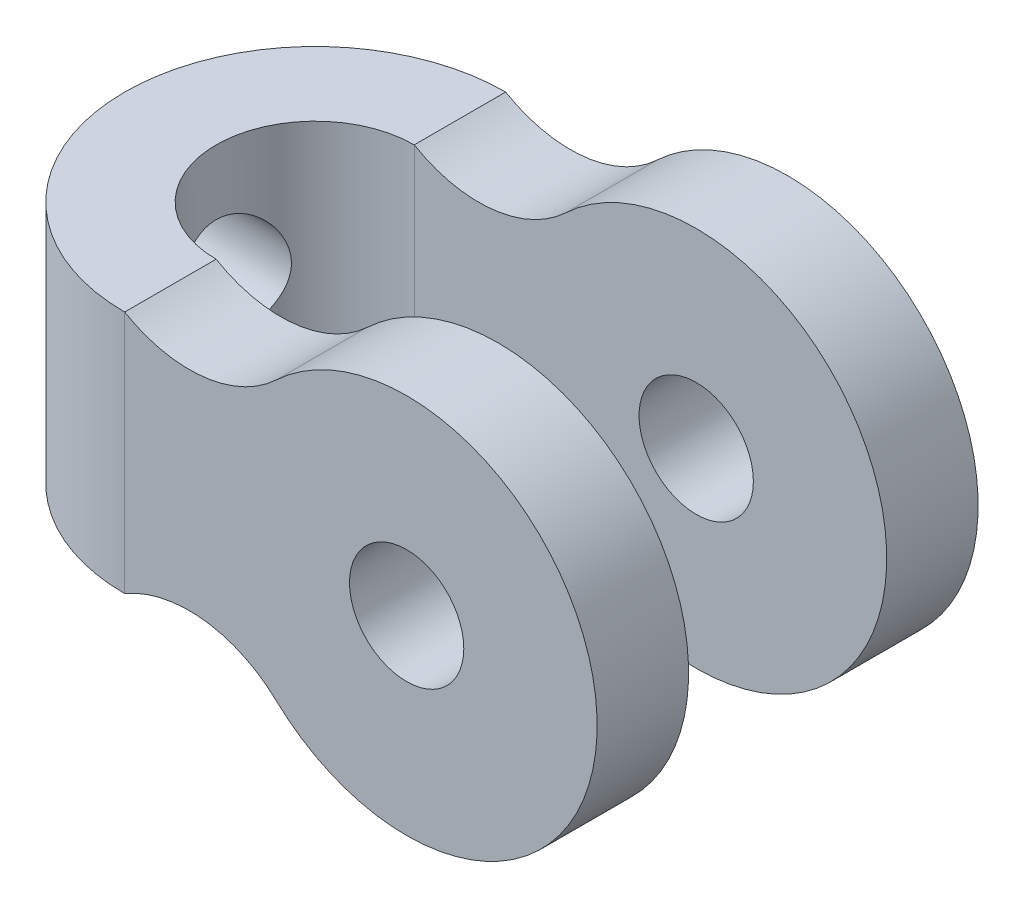
from build123d import *

# Parameters (mm, degrees)
BOSS_EXTRUDE1_DEPTH = 16
BOSS_EXTRUDE2_START = -27
SKETCH3_R           = 7.5
BOSS_EXTRUDE2_DEPTH = 27
SKETCH7_W           = 15
SKETCH7_H           = 50
CUT_EXTRUDE1_DEPTH  = 63
SKETCH8_R           = 7.5
BOSS_EXTRUDE6_DEPTH = 12
SKETCH9_R           = 7.5
CUT_EXTRUDE2_DEPTH  = 26


with BuildPart() as part:
    # Sketch1 → Boss-Extrude1 (new body, symmetric)
    with BuildSketch(Plane(origin=(0, 0, 0), x_dir=(1, 0, 0), z_dir=(0, 1, 0))):
        with BuildLine():
            Line((0, 13), (0, 25))
            ThreePointArc((0, 25), (-25, 0), (0, -25))
            Line((0, -25), (0, -13))
            ThreePointArc((0, -13), (-13, 0), (0, 13))
        make_face()
    extrude(amount=BOSS_EXTRUDE1_DEPTH, both=True)

    # Sketch3 → Boss-Extrude2 (add)
    with BuildSketch(Plane.XY.offset(40).offset(BOSS_EXTRUDE2_START)):
        with BuildLine():
            Line((0, 16), (0, -16))
            ThreePointArc((0, -16), (10.310830972, -13.799251334), (19.882176961, -18.220322017))
            ThreePointArc((19.882176961, -18.220322017), (62, 0), (19.882176961, 18.220322017))
            ThreePointArc((19.882176961, 18.220322017), (10.310830972, 13.799251334), (0, 16))
        make_face()
        with Locations((37, 0)):
            Circle(SKETCH3_R, mode=Mode.SUBTRACT)
    extrude(amount=BOSS_EXTRUDE2_DEPTH)

    # Sketch7 → Cut-Extrude1 (cut, through all)
    with BuildSketch(Plane.ZY):
        with Locations((32.5, 0)):
            Rectangle(SKETCH7_W, SKETCH7_H)
    extrude(amount=-CUT_EXTRUDE1_DEPTH, mode=Mode.SUBTRACT)

    # Sketch8 → Boss-Extrude6 (add)
    with BuildSketch(Plane.XY.offset(-25)):
        with BuildLine():
            Line((0, -16), (0, 16))
            ThreePointArc((0, 16), (10.310830972, 13.799251334), (19.882176961, 18.220322017))
            ThreePointArc((19.882176961, 18.220322017), (62, 0), (19.882176961, -18.220322017))
            ThreePointArc((19.882176961, -18.220322017), (10.310830972, -13.799251334), (0, -16))
        make_face()
        with Locations((37, 0)):
            Circle(SKETCH8_R, mode=Mode.SUBTRACT)
    extrude(amount=BOSS_EXTRUDE6_DEPTH)

    # Sketch9 → Cut-Extrude2 (cut, through all)
    with BuildSketch(Plane(origin=(0, 0, 0), x_dir=(0, 0, -1), z_dir=(1, 0, 0))):
        Circle(SKETCH9_R)
    extrude(amount=-CUT_EXTRUDE2_DEPTH, mode=Mode.SUBTRACT)


solid = part.part
